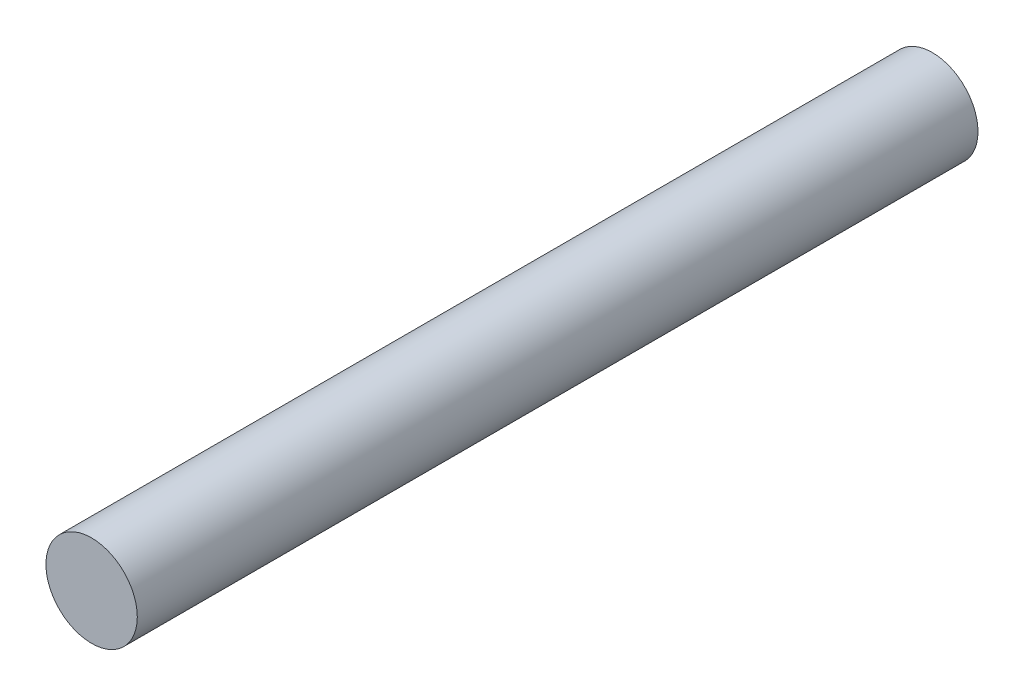
from build123d import *

# Parameters (mm, degrees)
SKETCH1_R           = 2.5
BOSS_EXTRUDE1_DEPTH = 46


with BuildPart() as part:
    # Sketch1 → Boss-Extrude1 (new body)
    with BuildSketch(Plane.XY):
        Circle(SKETCH1_R)
    extrude(amount=BOSS_EXTRUDE1_DEPTH)


solid = part.part
